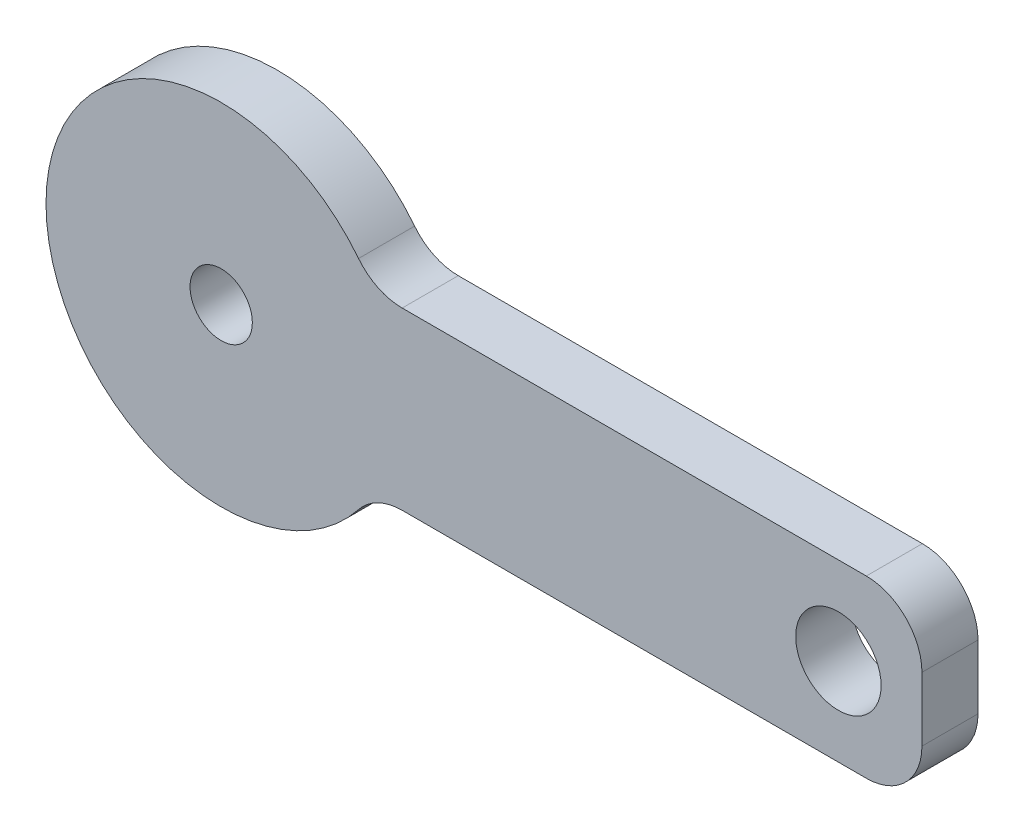
from build123d import *

# Parameters (mm, degrees)
BOSS_EXTRUDE1_DEPTH   = 1.6002
F_0_CLEARANCE_HOLE1_D = 1.778
F_2_CLEARANCE_HOLE1_D = 2.4384


with BuildPart() as part:
    # Sketch1 → Boss-Extrude1 (new body)
    with BuildSketch(Plane.XY):
        with BuildLine():
            Line((5.16599458, -2.5), (18.4125, -2.5))
            ThreePointArc((18.4125, -2.5), (19.535032015, -2.035032015), (20, -0.9125))
            Line((20, -0.9125), (20, 0.9125))
            ThreePointArc((20, 0.9125), (19.535032015, 2.035032015), (18.4125, 2.5))
            Line((18.4125, 2.5), (5.16599458, 2.5))
            ThreePointArc((5.16599458, 2.5), (4.474468718, 2.658532459), (3.921058505, 3.102466793))
            ThreePointArc((3.921058505, 3.102466793), (-5, 0), (3.921058505, -3.102466793))
            ThreePointArc((3.921058505, -3.102466793), (4.474468718, -2.658532459), (5.16599458, -2.5))
        make_face()
    extrude(amount=BOSS_EXTRUDE1_DEPTH)

    # #0 Clearance Hole1 (through all)
    with Locations(Plane.XY.offset(1.6002)):
        with Locations((0, 0)):
            Hole(F_0_CLEARANCE_HOLE1_D / 2)

    # #2 Clearance Hole1 (through all)
    with Locations(Plane.XY.offset(1.6002)):
        with Locations((17.615594793, 0)):
            Hole(F_2_CLEARANCE_HOLE1_D / 2)


solid = part.part
